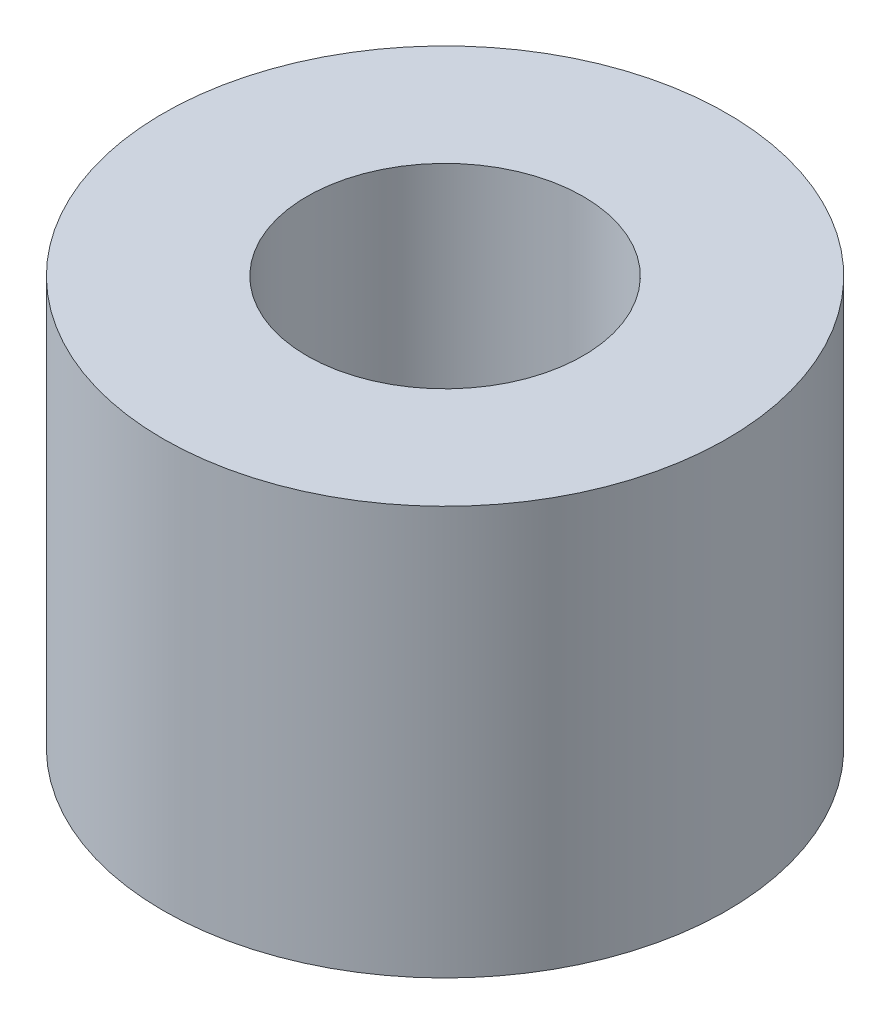
from build123d import *

# Parameters (mm, degrees)
SKETCH1_R           = 2.45
SKETCH1_R_2         = 1.2
BOSS_EXTRUDE1_DEPTH = 3.55


with BuildPart() as part:
    # Sketch1 → Boss-Extrude1 (new body)
    with BuildSketch(Plane(origin=(0, 0, 0), x_dir=(1, 0, 0), z_dir=(0, 1, 0))):
        Circle(SKETCH1_R)
        Circle(SKETCH1_R_2, mode=Mode.SUBTRACT)
    extrude(amount=BOSS_EXTRUDE1_DEPTH)


solid = part.part
